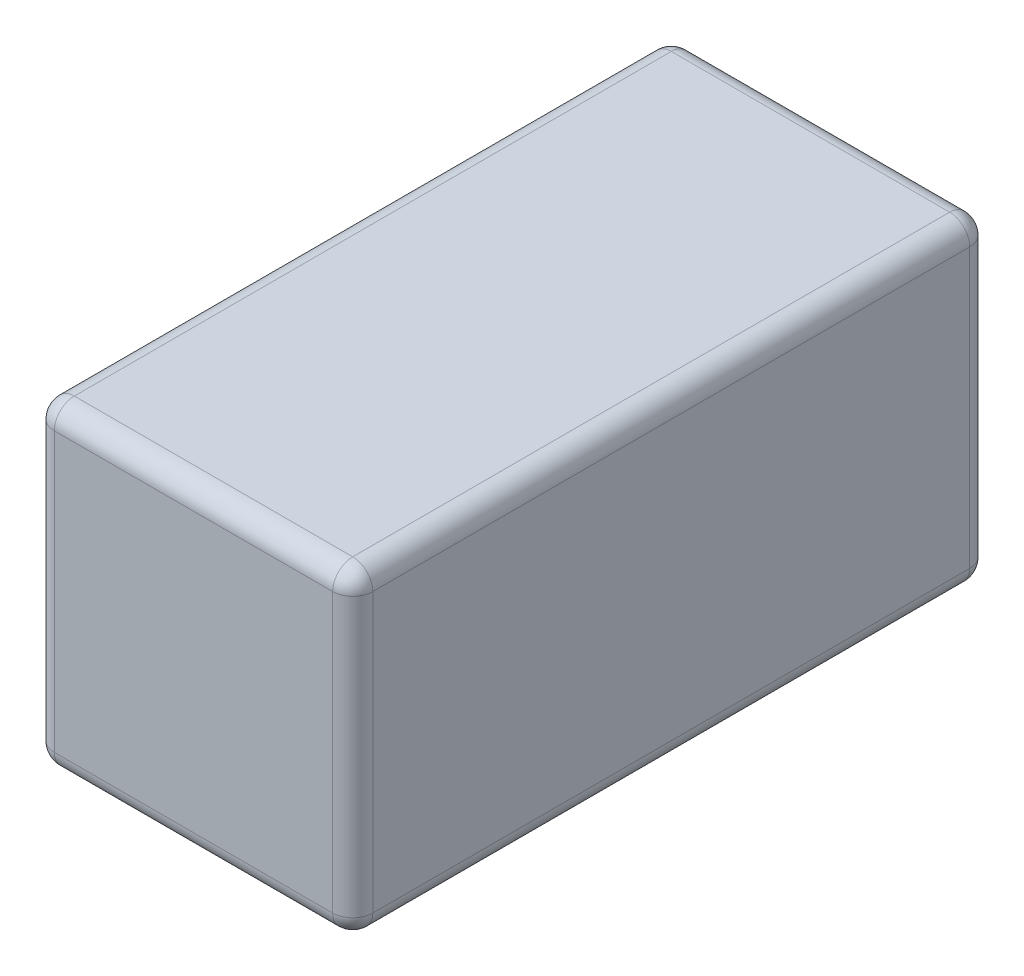
from build123d import *

# Parameters (mm, degrees)
SKETCH1_W           = 1.5875
SKETCH1_H           = 1.5875
BOSS_EXTRUDE1_DEPTH = 3.175
FILLET1_R           = 0.1


with BuildPart() as part:
    # Sketch1 → Boss-Extrude1 (new body)
    with BuildSketch(Plane.XY):
        Rectangle(SKETCH1_W, SKETCH1_H)
    extrude(amount=BOSS_EXTRUDE1_DEPTH)

    # Fillet1
    fillet1_edges = [part.edges().sort_by_distance(p)[0] for p in [
        (-0.79375, 0, 3.175),
        (0, -0.79375, 3.175),
        (0.79375, 0, 3.175),
        (0, -0.79375, 0),
        (-0.79375, 0, 0),
        (0, 0.79375, 0),
        (0.79375, 0, 0),
        (0.79375, -0.79375, 1.5875),
        (-0.79375, -0.79375, 1.5875),
        (-0.79375, 0.79375, 1.5875),
        (0.79375, 0.79375, 1.5875),
        (0, 0.79375, 3.175),
    ]]
    fillet(fillet1_edges, radius=FILLET1_R)


solid = part.part
